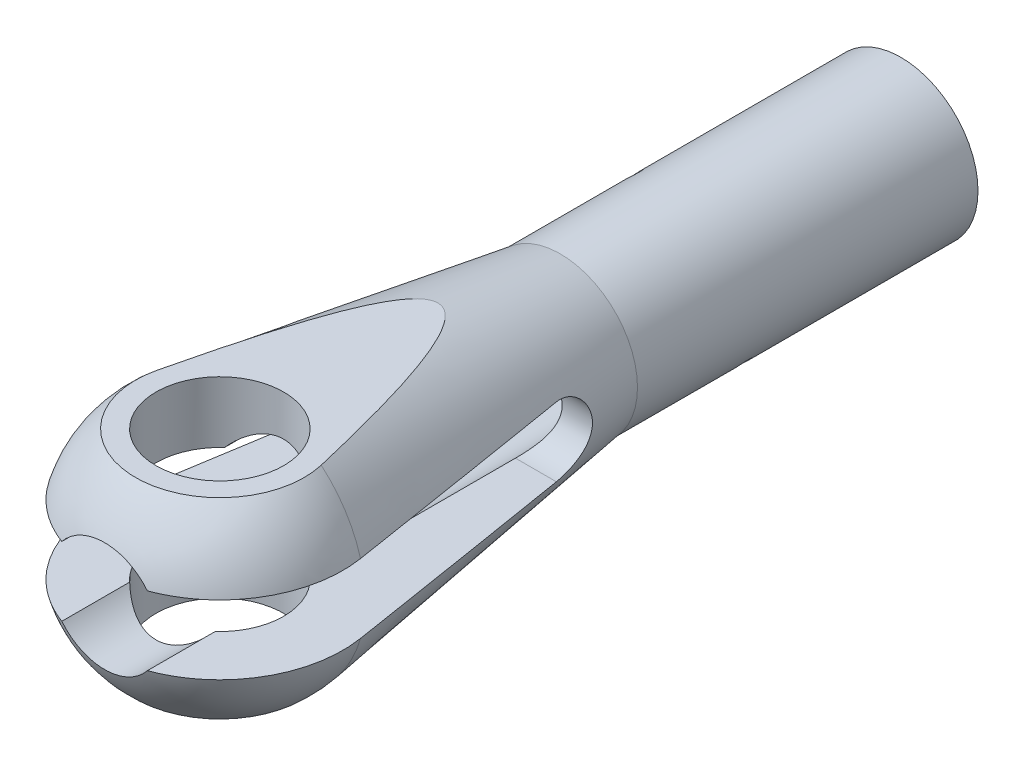
from build123d import *

# Parameters (mm, degrees)
SKETCH2_R                      = 3.4544
C_EXT_TAP_DRILL_DEPTH          = 14.3002
SKETCH3_R                      = 4.1021
C_EXT_ROD_CLEARANCE_HOLE_DEPTH = 47.0248
SKETCH6_R                      = 25.4
C_EXT_FLAT_DEPTH               = 3.3749
F_3_8_0_375_DIAMETER_HOLE1_D   = 9.525
C_EXT_SLOT_DEPTH               = 10.525
C_EXT_SLOT_DEPTH_BACK          = 10.525
SKETCH12_R                     = 0.5842
C_EXT_WITNESS_HOLE_DEPTH       = 12.539672719
C_EXT_WITNESS_HOLE_DEPTH_BACK  = 12.539672719


with BuildPart() as part:
    # Sketch1 → Revolve1 (revolve)
    with BuildSketch(Plane(origin=(0, 0, 0), x_dir=(0, 0, -1), z_dir=(1, 0, 0))):
        with BuildLine():
            Line((-9.525, 0), (50.8, 0))
            Line((50.8, 0), (50.8, 5.7531))
            Line((50.8, 5.7531), (25.4, 5.7531))
            Line((25.4, 5.7531), (1.439233062, 9.415637694))
            ThreePointArc((1.439233062, 9.415637694), (-6.205518918, 7.226144197), (-9.525, 0))
        make_face()
    revolve(axis=Axis((0, 0, 9.525), (0, 0, -1)))

    # Sketch2 → C-Ext Tap Drill (cut)
    with BuildSketch(Plane(origin=(0, 0, -50.8), x_dir=(-1, 0, 0), z_dir=(0, 0, -1))):
        Circle(SKETCH2_R)
    extrude(amount=-C_EXT_TAP_DRILL_DEPTH, mode=Mode.SUBTRACT)

    # Sketch3 → C-Ext Rod Clearance Hole (cut, through all)
    with BuildSketch(Plane(origin=(0, 0, -36.4998), x_dir=(-1, 0, 0), z_dir=(0, 0, -1))):
        Circle(SKETCH3_R)
    extrude(amount=-C_EXT_ROD_CLEARANCE_HOLE_DEPTH, mode=Mode.SUBTRACT)

    # Sketch6 → C-Ext Flat (cut, through all)
    with BuildSketch(Plane(origin=(0, 7.1501, 0), x_dir=(-1, 0, 0), z_dir=(0, 1, 0))):
        Circle(SKETCH6_R)
    c_ext_flat = extrude(amount=C_EXT_FLAT_DEPTH, mode=Mode.SUBTRACT)

    # Mirror Flat: C-Ext Flat across plane
    add(c_ext_flat.mirror(Plane.ZX), mode=Mode.SUBTRACT)

    # 3/8 (0.375) Diameter Hole1 (through all)
    with Locations(Plane(origin=(0, 7.1501, 0), x_dir=(-1, 0, 0), z_dir=(0, 1, 0))):
        with Locations((0, 0)):
            Hole(F_3_8_0_375_DIAMETER_HOLE1_D / 2)

    # Sketch9 → C-Ext Slot (cut, two sides)
    with BuildSketch(Plane(origin=(0, 0, 0), x_dir=(0, 0, -1), z_dir=(1, 0, 0))) as c_ext_slot_sk:
        with BuildLine():
            Line((-8.596417893, 2.5781), (18.8595, 2.5781))
            ThreePointArc((18.8595, 2.5781), (21.4376, 0), (18.8595, -2.5781))
            Line((18.8595, -2.5781), (-8.596417893, -2.5781))
            Line((-8.596417893, -2.5781), (-8.596417893, 2.5781))
        make_face()
    extrude(amount=C_EXT_SLOT_DEPTH, mode=Mode.SUBTRACT)
    extrude(c_ext_slot_sk.sketch, amount=-C_EXT_SLOT_DEPTH_BACK, mode=Mode.SUBTRACT)

    # Sketch13 → C-Rev Threads (revolve, cut)
    with BuildSketch(Plane(origin=(0, 0, 0), x_dir=(1, 0, 0), z_dir=(0, 1, 0))):
        Polygon((4.0767, 49.741666667), (3.160156448, 49.2125), (4.0767, 48.683333333), (3.160156448, 48.154166667), (4.0767, 47.625), (3.160156448, 47.095833333), (4.0767, 46.566666667), (3.160156448, 46.0375), (4.0767, 45.508333333), (3.160156448, 44.979166667), (4.0767, 44.45), (3.160156448, 43.920833333), (4.0767, 43.391666667), (3.160156448, 42.8625), (4.0767, 42.333333333), (3.160156448, 41.804166667), (4.0767, 41.275), (3.160156448, 40.745833333), (4.0767, 40.216666667), (3.160156448, 39.6875), (4.0767, 39.158333333), (3.160156448, 38.629166667), (4.0767, 38.1), (3.160156448, 37.570833333), (4.0767, 37.041666667), (3.160156448, 36.5125), (4.0767, 35.983333333), (3.160156448, 35.454166667), (4.0767, 34.925), (3.160156448, 34.395833333), (4.0767, 33.866666667), (3.160156448, 33.3375), (4.0767, 32.808333333), (3.160156448, 32.279166667), (4.0767, 31.75), (3.160156448, 31.220833333), (4.0767, 30.691666667), (3.160156448, 30.1625), (4.0767, 29.633333333), (3.160156448, 29.104166667), (4.0767, 28.575), (3.160156448, 28.045833333), (4.0767, 27.516666667), (3.160156448, 26.9875), (4.0767, 26.458333333), (3.160156448, 25.929166667), (4.0767, 25.4), (3.160156448, 24.870833333), (4.0767, 24.341666667), (3.160156448, 23.8125), (4.0767, 23.283333333), (3.160156448, 22.754166667), (4.0767, 22.225), (3.160156448, 21.695833333), (4.0767, 21.166666667), (3.160156448, 20.6375), (4.0767, 20.108333333), (3.160156448, 19.579166667), (4.0767, 19.05), (3.160156448, 18.520833333), (4.0767, 17.991666667), (3.160156448, 17.4625), (2.243612895, 17.4625), (2.243612895, 51.329166667), (3.160156448, 51.329166667), (4.0767, 50.8), (3.160156448, 50.270833333), align=None)
    revolve(axis=Axis((0, 0, -54.163040273), (0, 0, 1)), mode=Mode.SUBTRACT)

    # Sketch12 → C-Ext Witness Hole (cut, two sides)
    with BuildSketch(Plane(origin=(0, 0, 0), x_dir=(0.707106781, 0.707106781, 0), z_dir=(0.707106781, -0.707106781, 0))) as c_ext_witness_hole_sk:
        with Locations((0, -34.925)):
            Circle(SKETCH12_R)
    extrude(amount=C_EXT_WITNESS_HOLE_DEPTH, mode=Mode.SUBTRACT)
    extrude(c_ext_witness_hole_sk.sketch, amount=-C_EXT_WITNESS_HOLE_DEPTH_BACK, mode=Mode.SUBTRACT)


solid = part.part
